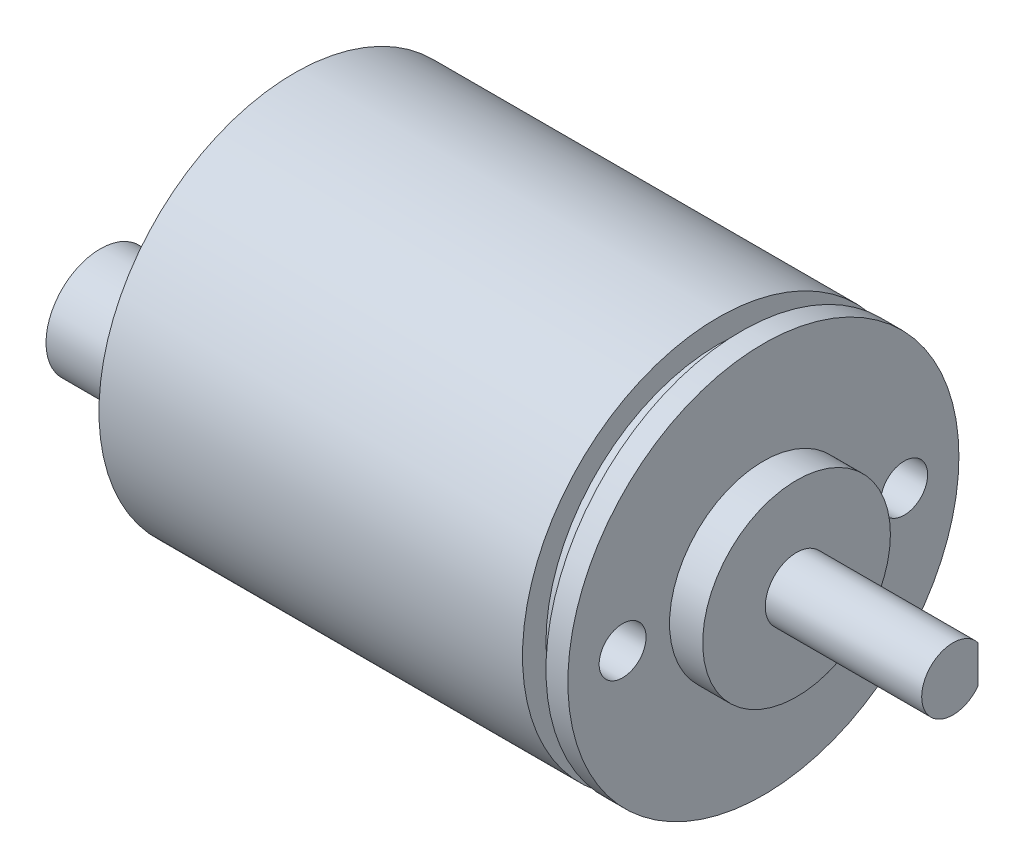
from build123d import *

# Parameters (mm, degrees)
SKETCH1_R           = 12.5
BOSS_EXTRUDE1_DEPTH = 27.0764
SKETCH2_R           = 11
BOSS_EXTRUDE2_DEPTH = 1.5
SKETCH3_R           = 12.5
BOSS_EXTRUDE3_DEPTH = 1.4
SKETCH4_R           = 6
BOSS_EXTRUDE4_DEPTH = 2.12
SKETCH5_R           = 2
BOSS_EXTRUDE5_DEPTH = 10
SKETCH6_W           = 2.63743778
SKETCH6_H           = 6.664381858
CUT_EXTRUDE1_DEPTH  = 8
SKETCH8_R           = 1.5
CUT_EXTRUDE2_DEPTH  = 6.35
SKETCH9_R           = 3.471368159
BOSS_EXTRUDE6_DEPTH = 5.5


with BuildPart() as part:
    # Sketch1 → Boss-Extrude1 (new body)
    with BuildSketch(Plane(origin=(0, 0, 0), x_dir=(0, 0, -1), z_dir=(1, 0, 0))):
        Circle(SKETCH1_R)
    extrude(amount=BOSS_EXTRUDE1_DEPTH)

    # Sketch2 → Boss-Extrude2 (add)
    with BuildSketch(Plane(origin=(27.0764, 0, 0), x_dir=(0, 0, -1), z_dir=(1, 0, 0))):
        Circle(SKETCH2_R)
    extrude(amount=BOSS_EXTRUDE2_DEPTH)

    # Sketch3 → Boss-Extrude3 (add)
    with BuildSketch(Plane(origin=(28.5764, 0, 0), x_dir=(0, 0, -1), z_dir=(1, 0, 0))):
        Circle(SKETCH3_R)
    extrude(amount=BOSS_EXTRUDE3_DEPTH)

    # Sketch4 → Boss-Extrude4 (add)
    with BuildSketch(Plane(origin=(29.9764, 0, 0), x_dir=(0, 0, -1), z_dir=(1, 0, 0))):
        Circle(SKETCH4_R)
    extrude(amount=BOSS_EXTRUDE4_DEPTH)

    # Sketch5 → Boss-Extrude5 (add)
    with BuildSketch(Plane(origin=(32.0964, 0, 0), x_dir=(0, 0, -1), z_dir=(1, 0, 0))):
        Circle(SKETCH5_R)
    extrude(amount=BOSS_EXTRUDE5_DEPTH)

    # Sketch6 → Cut-Extrude1 (cut)
    with BuildSketch(Plane(origin=(42.0964, 0, 0), x_dir=(0, 0, -1), z_dir=(1, 0, 0))):
        with Locations((2.91871889, -0.060449415)):
            Rectangle(SKETCH6_W, SKETCH6_H)
    extrude(amount=-CUT_EXTRUDE1_DEPTH, mode=Mode.SUBTRACT)

    # Sketch8 → Cut-Extrude2 (cut)
    with BuildSketch(Plane(origin=(29.9764, 0, 0), x_dir=(0, 0, -1), z_dir=(1, 0, 0))):
        with Locations((9, 0)):
            Circle(SKETCH8_R)
        with Locations((-9, 0)):
            Circle(SKETCH8_R)
    extrude(amount=-CUT_EXTRUDE2_DEPTH, mode=Mode.SUBTRACT)

    # Sketch9 → Boss-Extrude6 (add)
    with BuildSketch(Plane.ZY):
        with Locations((6.914557356, 0)):
            Circle(SKETCH9_R)
    extrude(amount=BOSS_EXTRUDE6_DEPTH)


solid = part.part
